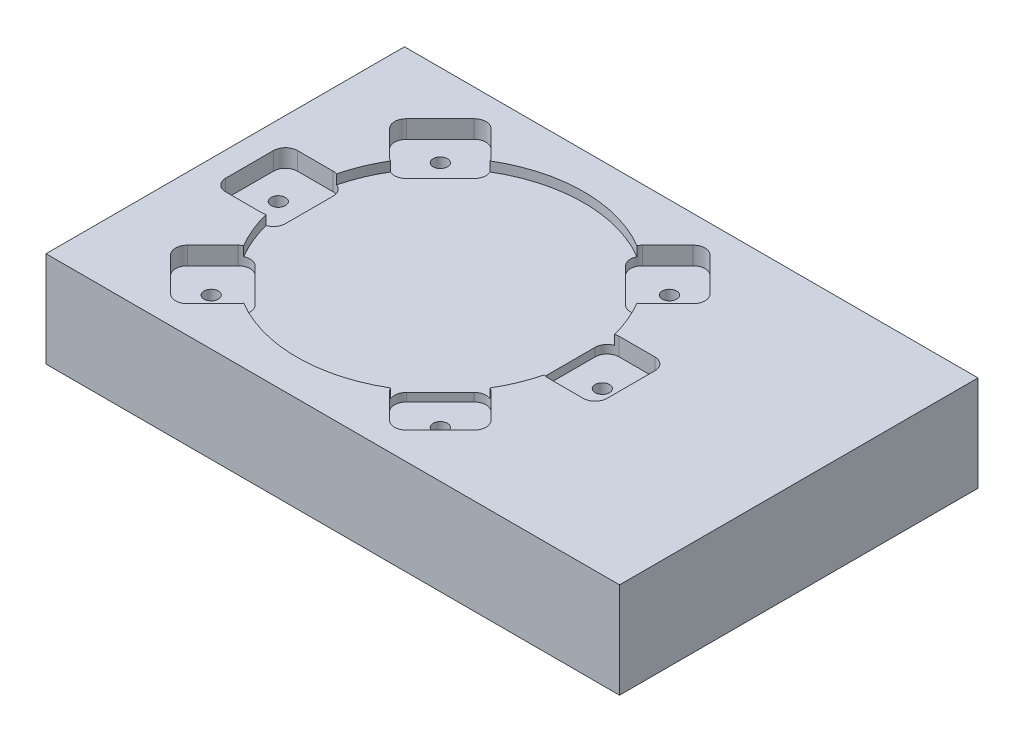
from build123d import *

# Parameters (mm, degrees)
SKETCH1_W                       = 152.4
SKETCH1_H                       = 95.25
BOSS_EXTRUDE1_DEPTH             = 25.4
SKETCH2_R                       = 38.1
F_3IN_POCKET_DEPTH              = 2.54
CLAMP_POCKET_DEPTH              = 4.7498
SKETCH4_R                       = 1.89865
NO25_THREAD_FORM_FOR_8_32_DEPTH = 20.6502
FOUR_CLAMPS_COUNT               = 4
F_180_CLAMP_COUNT               = 2
F_180_CLAMP_ANGLE               = 135
F_360_CLAMP_COUNT               = 2
F_360_CLAMP_ANGLE               = 315


with BuildPart() as part:
    # Sketch1 → Boss-Extrude1 (new body)
    with BuildSketch(Plane(origin=(0, 0, 0), x_dir=(1, 0, 0), z_dir=(0, 1, 0))):
        with Locations((76.2, 47.625)):
            Rectangle(SKETCH1_W, SKETCH1_H)
    extrude(amount=BOSS_EXTRUDE1_DEPTH)

    # Sketch2 → 3in Pocket (cut)
    with BuildSketch(Plane(origin=(0, 25.4, 0), x_dir=(1, 0, 0), z_dir=(0, 1, 0))):
        with Locations((57.15, 47.625)):
            Circle(SKETCH2_R)
    extrude(amount=-F_3IN_POCKET_DEPTH, mode=Mode.SUBTRACT)

    # Sketch3 → Clamp Pocket (cut)
    with BuildSketch(Plane(origin=(0, 25.4, 0), x_dir=(1, 0, 0), z_dir=(0, 1, 0))):
        with BuildLine():
            Line((90.736157893, 67.740773711), (97.471349984, 74.475965802))
            ThreePointArc((97.471349984, 74.475965802), (98.401285953, 76.721029832), (97.471349984, 78.966093863))
            Line((97.471349984, 78.966093863), (88.491093863, 87.946349984))
            ThreePointArc((88.491093863, 87.946349984), (86.246029832, 88.876285953), (84.000965802, 87.946349984))
            Line((84.000965802, 87.946349984), (77.265773711, 81.211157893))
            ThreePointArc((77.265773711, 81.211157893), (76.335837741, 78.966093863), (77.265773711, 76.721029832))
            Line((77.265773711, 76.721029832), (86.246029832, 67.740773711))
            ThreePointArc((86.246029832, 67.740773711), (88.491093863, 66.810837741), (90.736157893, 67.740773711))
        make_face()
    clamp_pocket = extrude(amount=-CLAMP_POCKET_DEPTH, mode=Mode.SUBTRACT)

    # Sketch4 → No25 Thread Form for 8-32 (cut)
    with BuildSketch(Plane(origin=(0, 20.6502, 0), x_dir=(1, 0, 0), z_dir=(0, 1, 0))):
        with Locations((87.59306825, 78.06806825)):
            Circle(SKETCH4_R)
    no25_thread_form_for_8_32 = extrude(amount=-NO25_THREAD_FORM_FOR_8_32_DEPTH, mode=Mode.SUBTRACT)

    # Four Clamps: Clamp Pocket, No25 Thread Form for 8-32 ×4 about axis
    four_clamps_axis = Axis((57.15, 0, -47.625), (0, 1, 0))
    for i in range(1, FOUR_CLAMPS_COUNT):
        add(clamp_pocket.rotate(four_clamps_axis, i * 360 / FOUR_CLAMPS_COUNT), mode=Mode.SUBTRACT)
        add(no25_thread_form_for_8_32.rotate(four_clamps_axis, i * 360 / FOUR_CLAMPS_COUNT), mode=Mode.SUBTRACT)

    # 180 Clamp: Clamp Pocket, No25 Thread Form for 8-32 ×2 about axis
    f_180_clamp_axis = Axis((57.15, 0, -47.625), (0, 1, 0))
    for i in range(1, F_180_CLAMP_COUNT):
        add(clamp_pocket.rotate(f_180_clamp_axis, i * F_180_CLAMP_ANGLE / (F_180_CLAMP_COUNT - 1)), mode=Mode.SUBTRACT)
        add(no25_thread_form_for_8_32.rotate(f_180_clamp_axis, i * F_180_CLAMP_ANGLE / (F_180_CLAMP_COUNT - 1)), mode=Mode.SUBTRACT)

    # 360 Clamp: Clamp Pocket, No25 Thread Form for 8-32 ×2 about axis
    f_360_clamp_axis = Axis((57.15, 25.4, -47.625), (0, 1, 0))
    for i in range(1, F_360_CLAMP_COUNT):
        add(clamp_pocket.rotate(f_360_clamp_axis, i * F_360_CLAMP_ANGLE / (F_360_CLAMP_COUNT - 1)), mode=Mode.SUBTRACT)
        add(no25_thread_form_for_8_32.rotate(f_360_clamp_axis, i * F_360_CLAMP_ANGLE / (F_360_CLAMP_COUNT - 1)), mode=Mode.SUBTRACT)


solid = part.part
